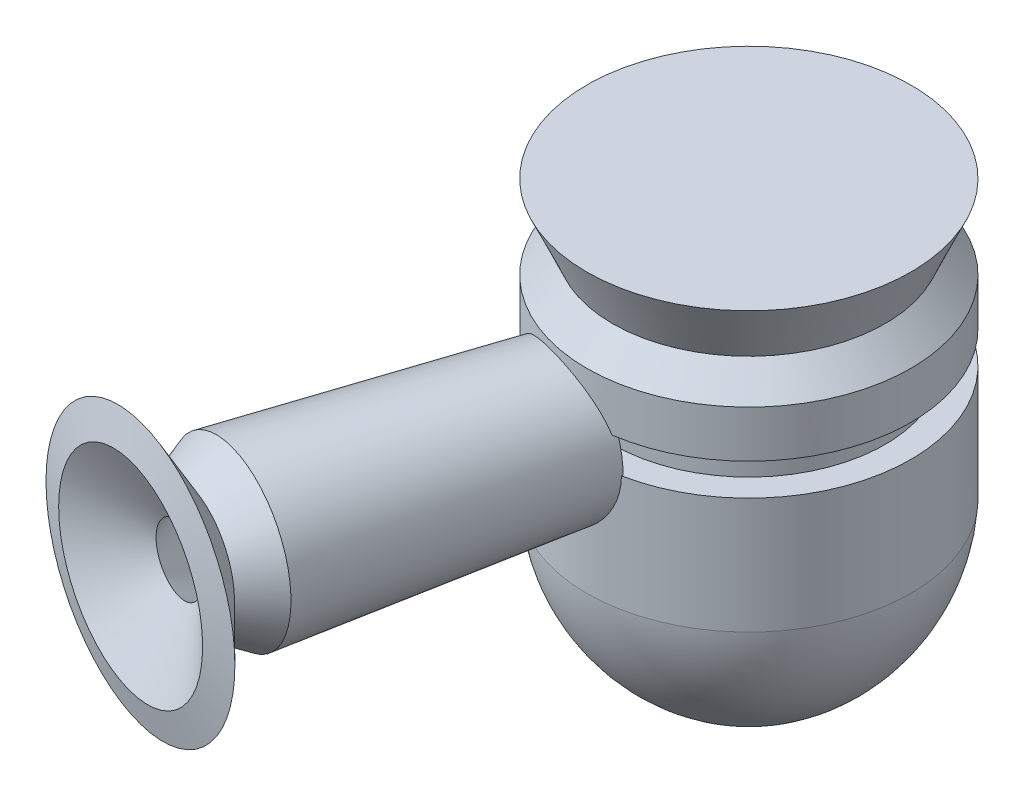
from build123d import *


with BuildPart() as part:
    # Sketch1 → Revolve1 (revolve)
    with BuildSketch(Plane.XY):
        with BuildLine():
            Line((18.654281973, 67.509460623), (18.654281973, 85.951651803))
            Line((18.654281973, 85.951651803), (14.554181768, 85.951651803))
            Line((14.554181768, 85.951651803), (14.554181768, 91.038742937))
            Line((14.554181768, 91.038742937), (18.654281973, 91.038742937))
            Line((18.654281973, 91.038742937), (18.654281973, 98.487697812))
            Line((18.654281973, 98.487697812), (14.554181768, 102.587798017))
            Line((14.554181768, 102.587798017), (18.654281973, 111.750471125))
            Line((18.654281973, 111.750471125), (-7.108349367, 111.750471125))
            Line((-7.108349367, 111.750471125), (-7.108349367, 98.487697812))
            Line((-7.108349367, 98.487697812), (7.996532166, 98.487697812))
            Line((7.996532166, 98.487697812), (7.996532166, 57.427605087))
            Line((7.996532166, 57.427605087), (0.444091399, 57.427605087))
            Line((0.444091399, 57.427605087), (0.444091399, 44.865685618))
            Line((0.444091399, 44.865685618), (4.926019535, 44.865685618))
            ThreePointArc((4.926019535, 44.865685618), (14.554181768, 54.511821478), (18.654281973, 67.509460623))
        make_face()
    revolve(axis=Axis((-7.108349367, 111.750471125, 0), (0, -1, 0)))

    # Sketch2 → Revolve2 (revolve)
    with BuildSketch(Plane(origin=(0, 85.951651803, 0), x_dir=(1, 0, 0), z_dir=(0, 1, 0))):
        Polygon((-12.941563399, -21.938938068), (-23.996434291, -19.455224522), (-36.865003284, -62.158981848), (-35.096912, -68.260719519), (-47.110720606, -71.741942645), (-42.631123157, -74.208704173), (-30.619424812, -70.728092534), (-32.80221788, -63.19520619), (-20.460781697, -37.558508231), (-17.141314342, -38.405147305), align=None)
    revolve(axis=Axis((-12.941563399, 85.951651803, 21.938938068), (-0.247140844, 0, 0.968979568)))


solid = part.part
